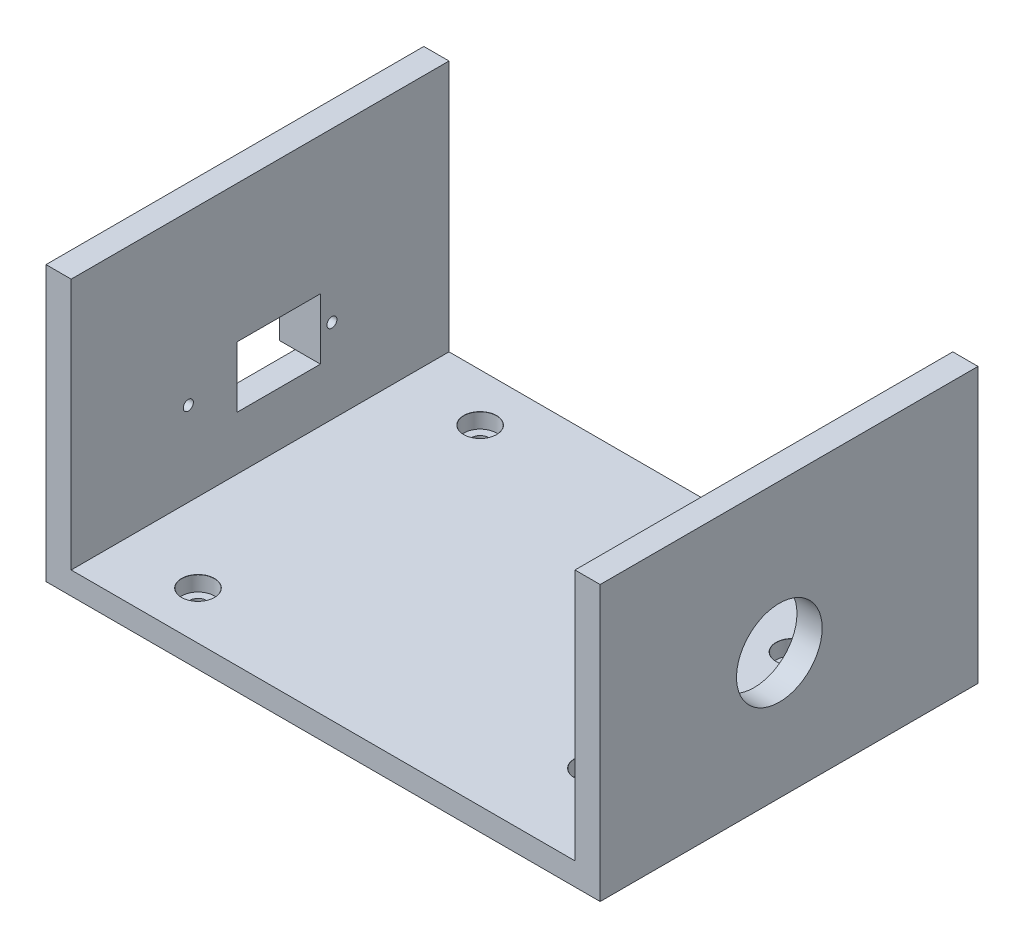
from build123d import *

# Parameters (mm, degrees)
SKETCH1_W                                      = 100
SKETCH1_H                                      = 75
BOSS_EXTRUDE1_DEPTH                            = 4.5
CBORE_FOR_M3_SOCKET_HEAD_CAP_SCREW1_AT_2_COUNT = 2
CBORE_FOR_M3_SOCKET_HEAD_CAP_SCREW1_AT_2_PITCH = 56
CBORE_FOR_M3_SOCKET_HEAD_CAP_SCREW1_AT_3_COUNT = 2
CBORE_FOR_M3_SOCKET_HEAD_CAP_SCREW1_AT_3_PITCH = 84.876380696
CBORE_FOR_M3_SOCKET_HEAD_CAP_SCREW1_AT_4_COUNT = 2
CBORE_FOR_M3_SOCKET_HEAD_CAP_SCREW1_AT_4_PITCH = 70.455659815
SKETCH5_W                                      = 5
SKETCH5_H                                      = 75
BOSS_EXTRUDE2_DEPTH                            = 50
BOSS_EXTRUDE2_DEPTH_BACK                       = 4.5
SKETCH7_W                                      = 4.5
SKETCH7_H                                      = 12.1
BOSS_EXTRUDE3_DEPTH                            = 3.1
SKETCH6_R                                      = 1
SKETCH6_W                                      = 16.599006094
SKETCH6_H                                      = 12.1
CUT_EXTRUDE1_DEPTH                             = 10
CUT_EXTRUDE1_DEPTH_BACK                        = 9.1
SKETCH8_R                                      = 8.5
CUT_EXTRUDE2_DEPTH                             = 9.1


with BuildPart() as part:
    # Sketch1 → Boss-Extrude1 (new body)
    with BuildSketch(Plane(origin=(0, 0, 0), x_dir=(1, 0, 0), z_dir=(0, 1, 0))):
        with Locations((11.109271523, 14.701986755)):
            Rectangle(SKETCH1_W, SKETCH1_H)
    extrude(amount=BOSS_EXTRUDE1_DEPTH)

    # Sketch4 → CBORE for M3 Socket Head Cap Screw1 (revolve, cut)
    with BuildSketch(Plane(origin=(-23.219008058, 4.5, -42.701986755), x_dir=(0, 0, 1), z_dir=(1, 0, 0))):
        Polygon((0, 0), (0, 4.5), (1.7, 4.5), (1.7, 3), (3.25, 3), (3.25, 0.025), (3.275, 0), align=None)
    cbore_for_m3_socket_head_cap_screw1 = revolve(axis=Axis((-23.219008058, 10.85, -42.701986755), (0, -1, 0)), mode=Mode.SUBTRACT)

    # CBORE for M3 Socket Head Cap Screw1 at 2: CBORE for M3 Socket Head Cap Screw1 ×2
    with Locations(*[(0, 0, i * CBORE_FOR_M3_SOCKET_HEAD_CAP_SCREW1_AT_2_PITCH) for i in range(1, CBORE_FOR_M3_SOCKET_HEAD_CAP_SCREW1_AT_2_COUNT)]):
        add(cbore_for_m3_socket_head_cap_screw1, mode=Mode.SUBTRACT)

    # CBORE for M3 Socket Head Cap Screw1 at 3: CBORE for M3 Socket Head Cap Screw1 ×2
    with Locations(*[Vector(0.824728852, 0, 0.565528356) * (i * CBORE_FOR_M3_SOCKET_HEAD_CAP_SCREW1_AT_3_PITCH) for i in range(1, CBORE_FOR_M3_SOCKET_HEAD_CAP_SCREW1_AT_3_COUNT)]):
        add(cbore_for_m3_socket_head_cap_screw1, mode=Mode.SUBTRACT)

    # CBORE for M3 Socket Head Cap Screw1 at 4: CBORE for M3 Socket Head Cap Screw1 ×2
    with Locations(*[Vector(0.993532673, 0, 0.113546591) * (i * CBORE_FOR_M3_SOCKET_HEAD_CAP_SCREW1_AT_4_PITCH) for i in range(1, CBORE_FOR_M3_SOCKET_HEAD_CAP_SCREW1_AT_4_COUNT)]):
        add(cbore_for_m3_socket_head_cap_screw1, mode=Mode.SUBTRACT)

    # Sketch5 → Boss-Extrude2 (add, two sides)
    with BuildSketch(Plane(origin=(0, 4.5, 0), x_dir=(1, 0, 0), z_dir=(0, 1, 0))) as boss_extrude2_sk:
        with Locations((-41.390728477, 14.701986755)):
            Rectangle(SKETCH5_W, SKETCH5_H)
        with Locations((63.609271523, 14.701986755)):
            Rectangle(SKETCH5_W, SKETCH5_H)
    extrude(amount=BOSS_EXTRUDE2_DEPTH)
    extrude(boss_extrude2_sk.sketch, amount=-BOSS_EXTRUDE2_DEPTH_BACK)

    # Sketch7 → Boss-Extrude3 (add)
    with BuildSketch(Plane.ZY.offset(43.890728477)):
        with Locations((-28.701986755, 21.2)):
            Rectangle(SKETCH7_W, SKETCH7_H)
        with Locations((-0.701986755, 21.2)):
            Rectangle(SKETCH7_W, SKETCH7_H)
    extrude(amount=BOSS_EXTRUDE3_DEPTH)

    # Sketch6 → Cut-Extrude1 (cut, two sides)
    with BuildSketch(Plane.ZY.offset(43.890728477)) as cut_extrude1_sk:
        with Locations((-28.951986755, 21.2)):
            Circle(SKETCH6_R)
        with Locations((-0.451986755, 21.2)):
            Circle(SKETCH6_R)
        with Locations((-18.371105673, 21.2)):
            Rectangle(SKETCH6_W, SKETCH6_H)
    extrude(amount=CUT_EXTRUDE1_DEPTH, mode=Mode.SUBTRACT)
    extrude(cut_extrude1_sk.sketch, amount=-CUT_EXTRUDE1_DEPTH_BACK, mode=Mode.SUBTRACT)

    # Sketch8 → Cut-Extrude2 (cut)
    with BuildSketch(Plane(origin=(66.109271523, 0, 0), x_dir=(0, 0, -1), z_dir=(1, 0, 0))):
        with Locations((12.767684718, 25)):
            Circle(SKETCH8_R)
    extrude(amount=-CUT_EXTRUDE2_DEPTH, mode=Mode.SUBTRACT)


solid = part.part
